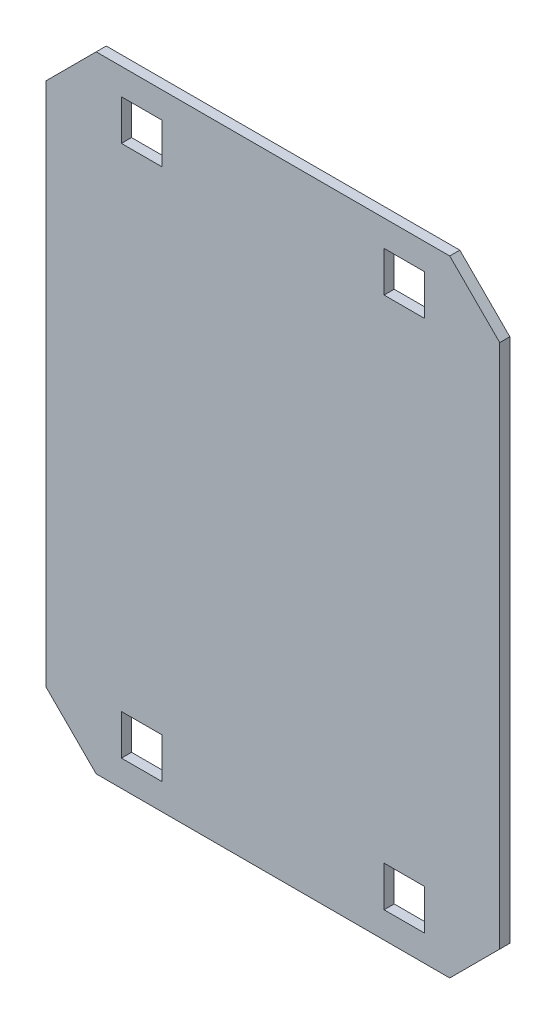
from build123d import *

# Parameters (mm, degrees)
BOSS_EXTRU_1_DEPTH      = 5
ESQUISSE2_W             = 20
ESQUISSE2_H             = 20
ENL_V_MAT_EXTRU_1_DEPTH = 5


with BuildPart() as part:
    # Esquisse1 → Boss.-Extru.1 (new body)
    with BuildSketch(Plane.XY):
        Polygon((-112.248737342, -130), (-87.5, -154.748737342), (87.5, -154.748737342), (112.248737342, -130), (112.248737342, 130), (87.5, 154.748737342), (-87.5, 154.748737342), (-112.248737342, 130), align=None)
    extrude(amount=BOSS_EXTRU_1_DEPTH)

    # Esquisse2 → Enlèv. mat.-Extru.1 (cut)
    with BuildSketch(Plane.XY.offset(5)):
        with Locations((-65, 131.748737342)):
            Rectangle(ESQUISSE2_W, ESQUISSE2_H)
        with Locations((-65, -131.748737342)):
            Rectangle(ESQUISSE2_W, ESQUISSE2_H)
        with Locations((65, -131.748737342)):
            Rectangle(ESQUISSE2_W, ESQUISSE2_H)
        with Locations((65, 131.748737342)):
            Rectangle(ESQUISSE2_W, ESQUISSE2_H)
    extrude(amount=-ENL_V_MAT_EXTRU_1_DEPTH, mode=Mode.SUBTRACT)


solid = part.part
